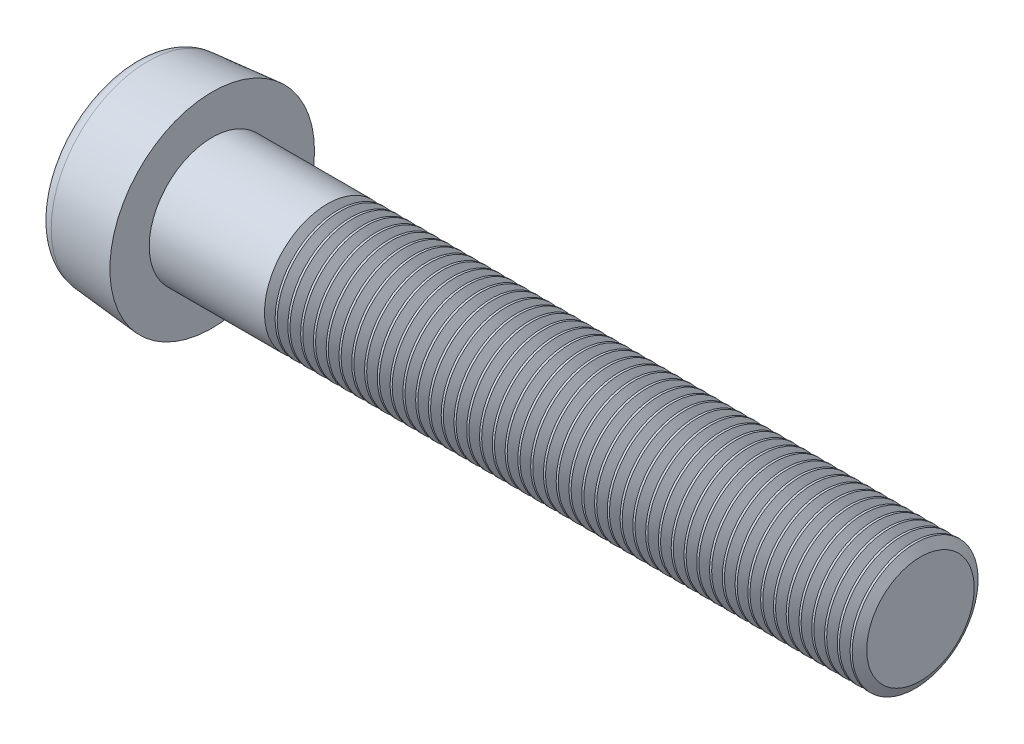
from build123d import *

# Parameters (mm, degrees)
SKETCH1_R        = 6.5
BASEHEAD_DEPTH   = 5
BASEHEAD_DRAFT   = -5
SKETCH8_W        = 45
SKETCH8_H        = 4
SOCKET_DEPTH     = 2.6
HEADFILLET2_R    = 1
LPATTERN10_COUNT = 47
LPATTERN10_PITCH = 0.8118


with BuildPart() as part:
    # Sketch1 → BaseHead (with draft: the straight prism first)
    with BuildSketch(Plane(origin=(5, 0, 0), x_dir=(0, 0, -1), z_dir=(1, 0, 0))):
        Circle(SKETCH1_R)
    extrude(amount=-BASEHEAD_DEPTH)
    # BaseHead: the draft: its side faces are tilted about the plane it starts from
    basehead_sides = [part.faces().sort_by_distance(p)[0] for p in [
        (2.5, 0, 6.5),
    ]]
    draft(basehead_sides, Plane(origin=(5, 0, 0), x_dir=(0, 0, -1), z_dir=(1, 0, 0)), BASEHEAD_DRAFT)

    # Sketch8 → Revolve1 (revolve)
    with BuildSketch(Plane.XY, mode=Mode.PRIVATE) as revolve1_sk:
        with Locations((27.5, 2)):
            Rectangle(SKETCH8_W, SKETCH8_H)
    revolve(revolve1_sk.sketch.rotate(Axis((0, 0, 0), (1, 0, 0)), 90), axis=Axis((0, 0, 0), (1, 0, 0)))

    # Sketch4 → Socket (cut)
    with BuildSketch(Plane(origin=(0, 0, 0), x_dir=(0, 0, -1), z_dir=(1, 0, 0))):
        with BuildLine():
            add(Edge.make_bspline(
                [(1.25, 2.165063509), (1.730769231, 1.887491265), (2.884615385, 1.665433469), (2.307692308, 0), (2.884615385, -1.665433469), (1.153846154, -1.998520163), (0, -3.330866938), (-1.153846154, -1.998520163), (-2.884615385, -1.665433469), (-2.307692308, 0), (-2.884615385, 1.665433469), (-1.153846154, 1.998520163), (0, 3.330866938), (0.769230769, 2.442635754), (1.25, 2.165063509)],
                knots=[0, 0, 0, 0, 0.083333333, 0.166666667, 0.25, 0.333333333, 0.416666667, 0.5, 0.583333333, 0.666666667, 0.75, 0.833333333, 0.916666667, 1, 1, 1, 1], degree=3))
        make_face()
    extrude(amount=SOCKET_DEPTH, mode=Mode.SUBTRACT)

    # Sketch5 → Cut-Loft1 section 0
    with BuildSketch(Plane.ZY.offset(-2.6), mode=Mode.PRIVATE) as cut_loft1_s0:
        with BuildLine():
            add(Edge.make_bspline(
                [(-1.25, 2.165063509), (-1.730769231, 1.887491265), (-2.884615385, 1.665433469), (-2.307692308, 0), (-2.884615385, -1.665433469), (-1.153846154, -1.998520163), (0, -3.330866938), (1.153846154, -1.998520163), (2.884615385, -1.665433469), (2.307692308, 0), (2.884615385, 1.665433469), (1.153846154, 1.998520163), (0, 3.330866938), (-0.769230769, 2.442635754), (-1.25, 2.165063509)],
                knots=[0, 0, 0, 0, 0.083333333, 0.166666667, 0.25, 0.333333333, 0.416666667, 0.5, 0.583333333, 0.666666667, 0.75, 0.833333333, 0.916666667, 1, 1, 1, 1], degree=3))
        make_face()
    loft([Vertex(3.466666667, 0, 0), cut_loft1_s0.sketch], mode=Mode.SUBTRACT)

    # HeadFillet2
    headfillet2_edges = [part.edges().sort_by_distance(p)[0] for p in [
        (0, 0, 6.062556682),
    ]]
    fillet(headfillet2_edges, radius=HEADFILLET2_R)

    # Sketch9 → Cut-Revolve10 (revolve, cut)
    with BuildSketch(Plane.XY, mode=Mode.PRIVATE) as cut_revolve10_sk:
        Polygon((50, 3.414133814), (50.33825, 4), (50.33825, 4.6765), (49.66175, 4.6765), (49.66175, 4), align=None)
    cut_revolve10 = revolve(cut_revolve10_sk.sketch.rotate(Axis((0, 0, 0), (1, 0, 0)), 90), axis=Axis((0, 0, 0), (1, 0, 0)), mode=Mode.SUBTRACT)

    # LPattern10: Cut-Revolve10 ×47
    with Locations(*[(-i * LPATTERN10_PITCH, 0, 0) for i in range(1, LPATTERN10_COUNT)]):
        add(cut_revolve10, mode=Mode.SUBTRACT)


solid = part.part
